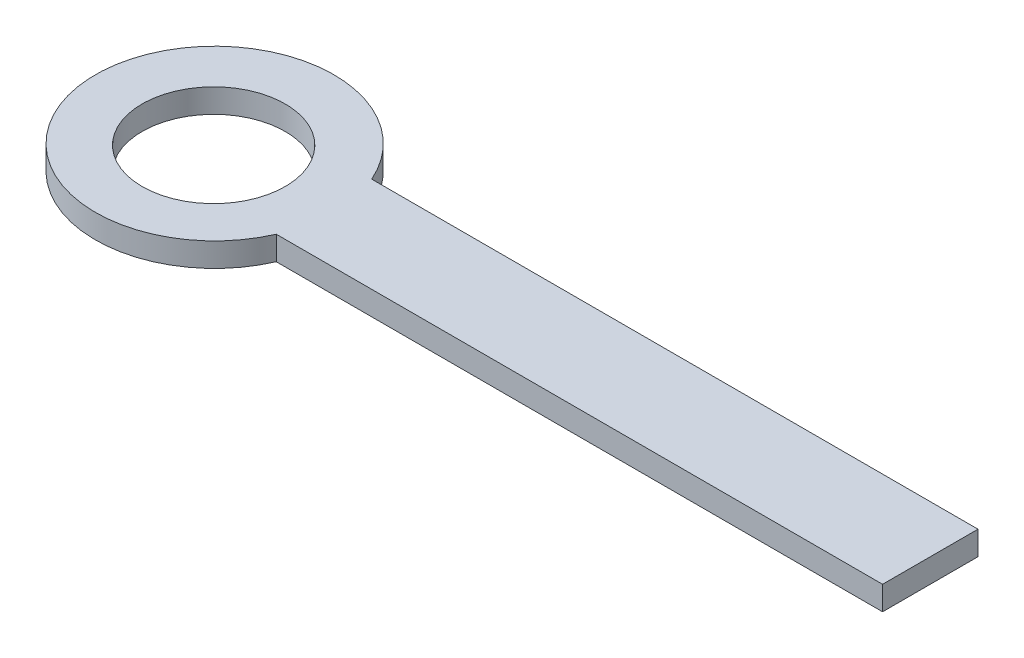
from build123d import *

# Parameters (mm, degrees)
BOSS_EXTRUDE1_DEPTH = 10
SKETCH2_R           = 30
CUT_EXTRUDE1_DEPTH  = 11


with BuildPart() as part:
    # Sketch1 → Boss-Extrude1 (new body)
    with BuildSketch(Plane(origin=(0, 0, 0), x_dir=(1, 0, 0), z_dir=(0, 1, 0))):
        with BuildLine():
            Line((-53.449605369, 12.68115942), (200.724637681, 12.68115942))
            Line((200.724637681, 12.68115942), (200.724637681, -27.31884058))
            Line((200.724637681, -27.31884058), (-53.449605369, -27.31884058))
            ThreePointArc((-53.449605369, -27.31884058), (-149.275362319, -7.31884058), (-53.449605369, 12.68115942))
        make_face()
    extrude(amount=BOSS_EXTRUDE1_DEPTH)

    # Sketch2 → Cut-Extrude1 (cut, through all)
    with BuildSketch(Plane(origin=(0, 10, 0), x_dir=(1, 0, 0), z_dir=(0, 1, 0))):
        with Locations((-98.874058495, -8.131832766)):
            Circle(SKETCH2_R)
    extrude(amount=-CUT_EXTRUDE1_DEPTH, mode=Mode.SUBTRACT)


solid = part.part
